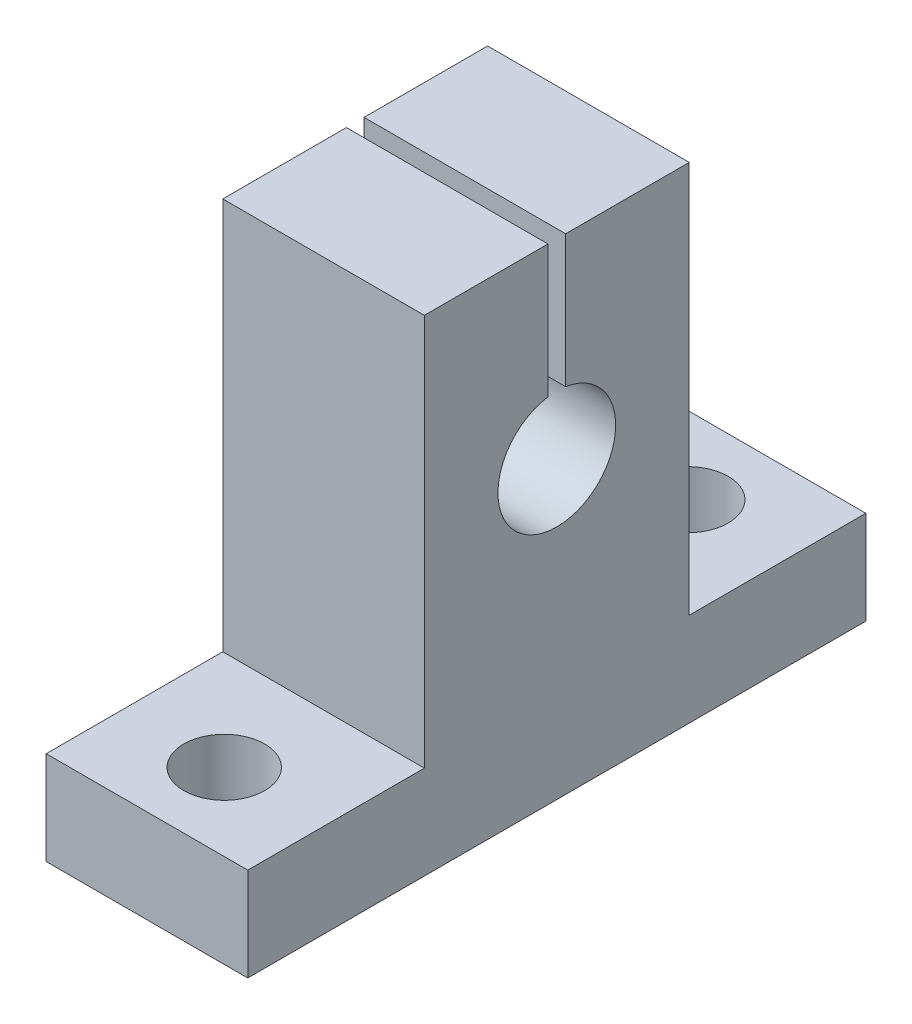
from build123d import *

# Parameters (mm, degrees)
SKETCH1_W           = 13.7
SKETCH1_H           = 42
BOSS_EXTRUDE1_DEPTH = 6.35
SKETCH2_W           = 13.7
SKETCH2_H           = 18
BOSS_EXTRUDE2_DEPTH = 26.65
CUT_EXTRUDE1_DEPTH  = 14.7
SKETCH4_R           = 2.75
CUT_EXTRUDE2_DEPTH  = 7.35


with BuildPart() as part:
    # Sketch1 → Boss-Extrude1 (new body)
    with BuildSketch(Plane(origin=(0, 0, 0), x_dir=(1, 0, 0), z_dir=(0, 1, 0))):
        Rectangle(SKETCH1_W, SKETCH1_H)
    extrude(amount=BOSS_EXTRUDE1_DEPTH)

    # Sketch2 → Boss-Extrude2 (add)
    with BuildSketch(Plane(origin=(0, 6.35, 0), x_dir=(1, 0, 0), z_dir=(0, 1, 0))):
        Rectangle(SKETCH2_W, SKETCH2_H)
    extrude(amount=BOSS_EXTRUDE2_DEPTH)

    # Sketch3 → Cut-Extrude1 (cut, through all)
    with BuildSketch(Plane.ZY.offset(6.85)):
        with BuildLine():
            Line((-0.6, 24), (-0.6, 33))
            Line((-0.6, 33), (0.6, 33))
            Line((0.6, 33), (0.6, 24))
            ThreePointArc((0.6, 24), (0, 16.045256013), (-0.6, 24))
        make_face()
    extrude(amount=-CUT_EXTRUDE1_DEPTH, mode=Mode.SUBTRACT)

    # Sketch4 → Cut-Extrude2 (cut, through all)
    with BuildSketch(Plane(origin=(0, 6.35, 0), x_dir=(1, 0, 0), z_dir=(0, 1, 0))):
        with Locations((0, -15.75)):
            Circle(SKETCH4_R)
    cut_extrude2 = extrude(amount=-CUT_EXTRUDE2_DEPTH, mode=Mode.SUBTRACT)

    # Mirror1: Cut-Extrude2 across plane
    add(cut_extrude2.mirror(Plane.XY), mode=Mode.SUBTRACT)


solid = part.part
